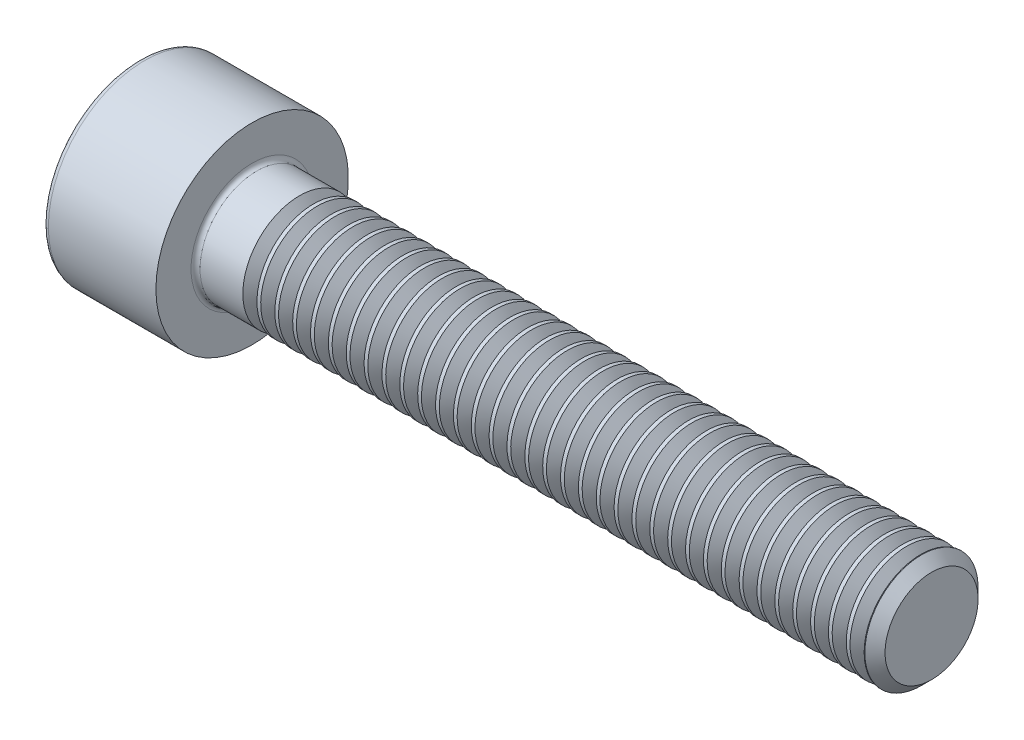
from build123d import *

# Parameters (mm, degrees)
FILLET1_R       = 0.2
FILLET2_R       = 0.25
HEX_2_DEPTH     = 2.5
THDSCHPAT_COUNT = 36
THDSCHPAT_PITCH = 0.788571429


with BuildPart() as part:
    # BodySke → Base-Revolve (revolve)
    with BuildSketch(Plane.XY):
        Polygon((0, 0), (0, 4.25), (5, 4.25), (5, 2.5), (34.555, 2.5), (35, 2.055), (35, 0), align=None)
    revolve(axis=Axis((-31.75, 0, 0), (1, 0, 0)))

    # Fillet1
    fillet1_edges = [part.edges().sort_by_distance(p)[0] for p in [
        (5, -2.5, 0),
    ]]
    fillet(fillet1_edges, radius=FILLET1_R)

    # Fillet2
    fillet2_edges = [part.edges().sort_by_distance(p)[0] for p in [
        (0, -4.25, 0),
    ]]
    fillet(fillet2_edges, radius=FILLET2_R)

    # Sketch2 → Hex-PreBroach (revolve, cut)
    with BuildSketch(Plane.XY):
        Polygon((0, 2.042), (2.5, 2.042), (3.67894925, 0), (0, 0), align=None)
    revolve(axis=Axis((0, 0, 0), (1, 0, 0)), mode=Mode.SUBTRACT)

    # Sketch3 → Hex 2 (cut)
    with BuildSketch(Plane(origin=(0, 0, 0), x_dir=(0, 0.5, 0.866025404), z_dir=(-1, 0, 0))):
        Polygon((1.17894925, 2.042), (-1.17894925, 2.042), (-2.357898499, 0), (-1.17894925, -2.042), (1.17894925, -2.042), (2.357898499, 0), align=None)
    extrude(amount=-HEX_2_DEPTH, mode=Mode.SUBTRACT)

    # ThdSchSke → ThreadSchematic (revolve, cut)
    with BuildSketch(Plane.XY):
        Polygon((7.4, -2.055), (7.088407645, -2.5), (7.088407645, -3.125), (7.711592355, -3.125), (7.711592355, -2.5), align=None)
    threadschematic = revolve(axis=Axis((-3.175, 0, 0), (1, 0, 0)), mode=Mode.SUBTRACT)

    # ThdSchPat: ThreadSchematic ×36
    with Locations(*[(i * THDSCHPAT_PITCH, 0, 0) for i in range(1, THDSCHPAT_COUNT)]):
        add(threadschematic, mode=Mode.SUBTRACT)


solid = part.part
